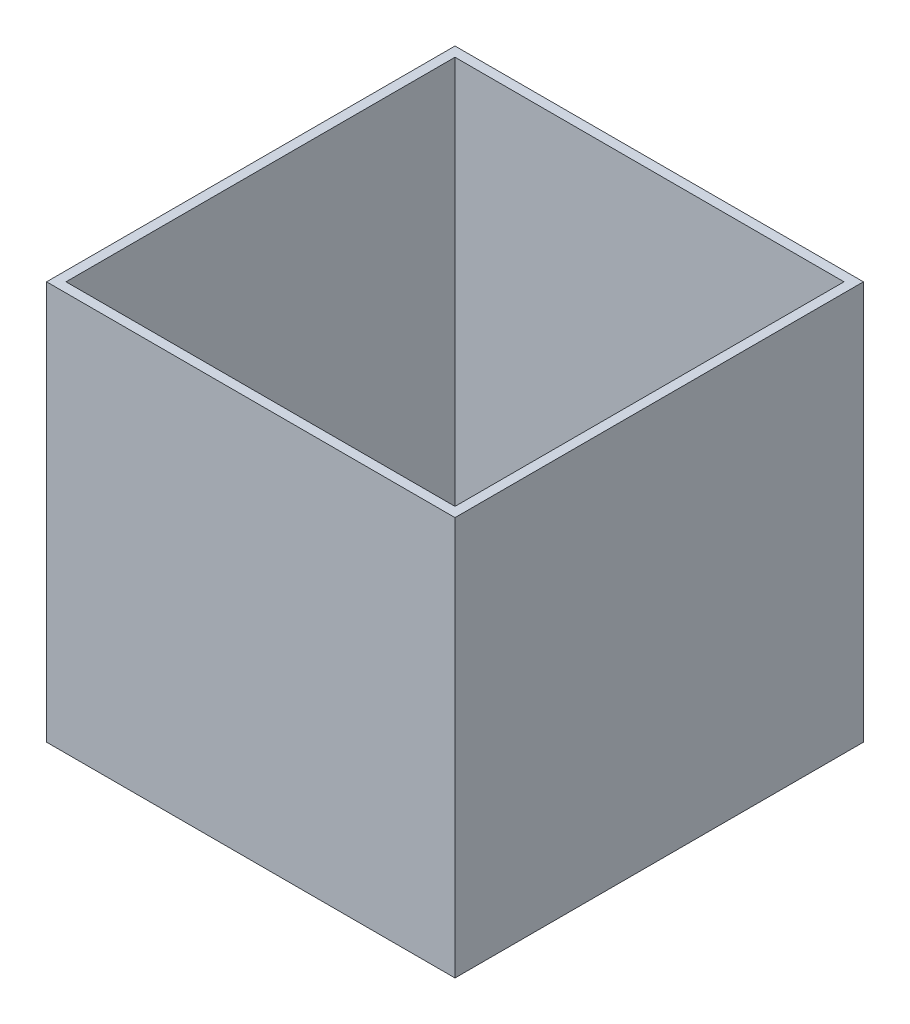
from build123d import *

# Parameters (mm, degrees)
SKETCH1_W           = 420
SKETCH1_H           = 420
BOSS_EXTRUDE1_DEPTH = 10
SKETCH2_W           = 420
SKETCH2_H           = 420
SKETCH2_W_2         = 400
SKETCH2_H_2         = 400
BOSS_EXTRUDE2_DEPTH = 400


with BuildPart() as part:
    # Sketch1 → Boss-Extrude1 (new body)
    with BuildSketch(Plane(origin=(0, 0, 0), x_dir=(1, 0, 0), z_dir=(0, 1, 0))):
        with Locations((210, 210)):
            Rectangle(SKETCH1_W, SKETCH1_H)
    extrude(amount=BOSS_EXTRUDE1_DEPTH)

    # Sketch2 → Boss-Extrude2 (add)
    with BuildSketch(Plane(origin=(0, 10, 0), x_dir=(1, 0, 0), z_dir=(0, 1, 0))):
        with Locations((210, 210)):
            Rectangle(SKETCH2_W, SKETCH2_H)
        with Locations((210, 210)):
            Rectangle(SKETCH2_W_2, SKETCH2_H_2, mode=Mode.SUBTRACT)
    extrude(amount=BOSS_EXTRUDE2_DEPTH)


solid = part.part
